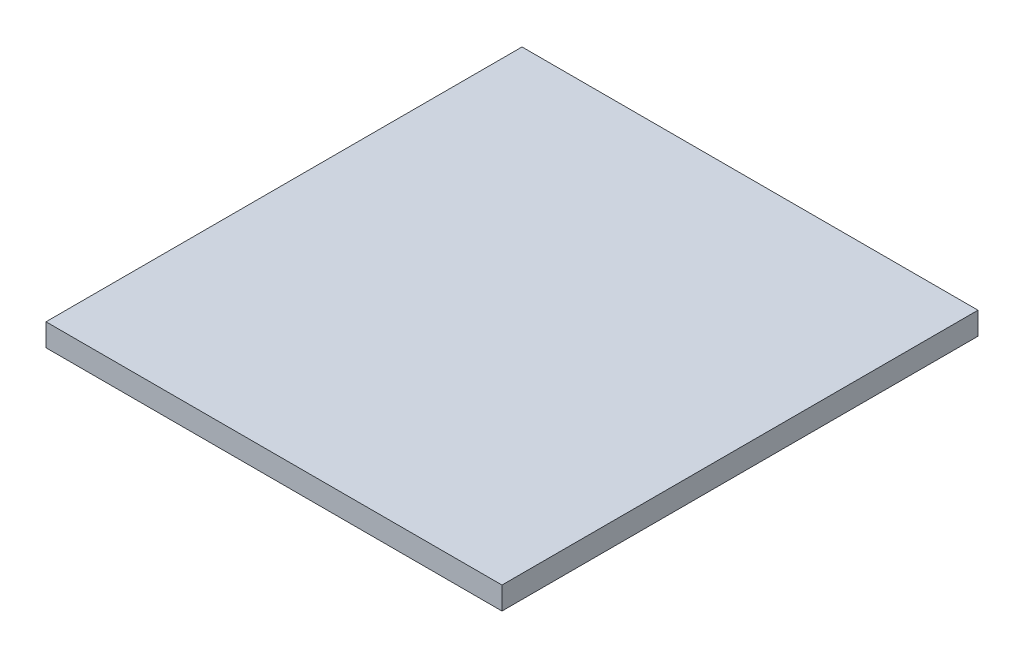
from build123d import *

# Parameters (mm, degrees)
SKETCH1_W           = 364
SKETCH1_H           = 380
BOSS_EXTRUDE1_DEPTH = 18


with BuildPart() as part:
    # Sketch1 → Boss-Extrude1 (new body)
    with BuildSketch(Plane(origin=(0, 0, 0), x_dir=(1, 0, 0), z_dir=(0, 1, 0))):
        with Locations((143.575632918, 172.94428604)):
            Rectangle(SKETCH1_W, SKETCH1_H)
    extrude(amount=BOSS_EXTRUDE1_DEPTH)


solid = part.part
